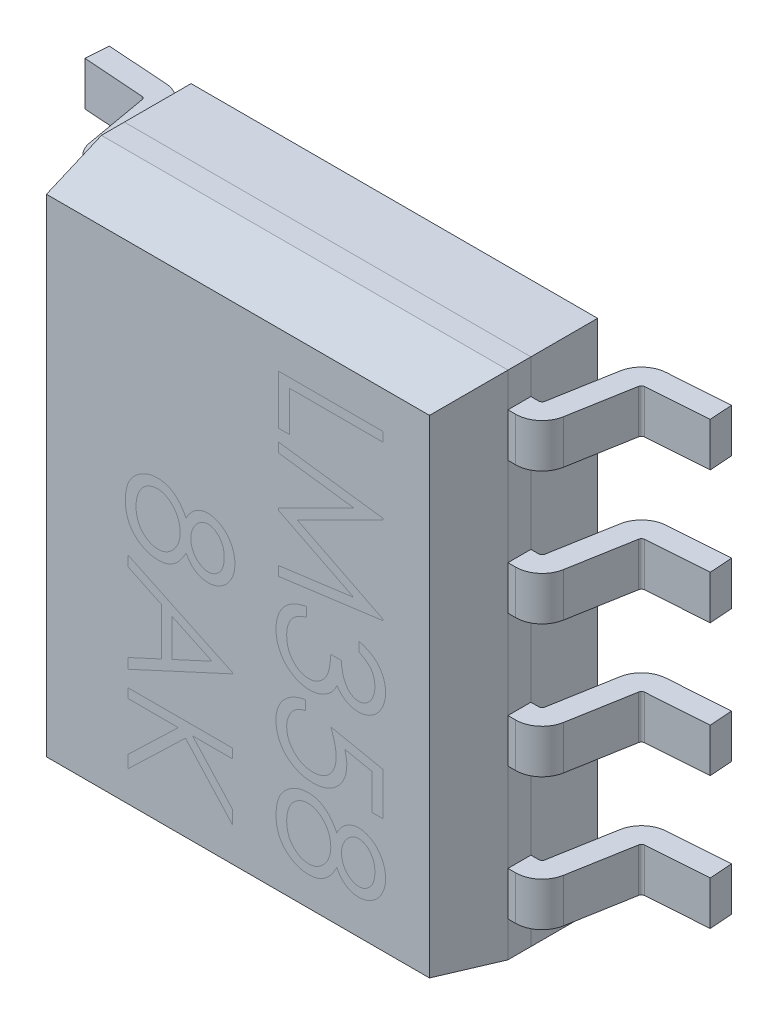
from build123d import *

# Parameters (mm, degrees)
SZKIC1_W                      = 3.9
SZKIC1_H                      = 4.9
DODANIE_WYCI_GNI_CIE1_DEPTH   = 0.22
DODANIE_WYCI_GNI_CIE2_DEPTH   = 0.42
DODANIE_WYCI_GNI_CIE2_2_DEPTH = 0.42
SZYK_LINIOWY1_COUNT           = 4
SZYK_LINIOWY1_PITCH           = 1.27
SZKIC3_W                      = 3.9
SZKIC3_H                      = 4.9
DODANIE_WYCI_GNI_CIE3_DEPTH   = 0.64
DODANIE_WYCI_GNI_CIE3_TAPER   = 10
SZKIC4_W                      = 3.9
SZKIC4_H                      = 4.9
DODANIE_WYCI_GNI_CIE4_DEPTH   = 0.64


with BuildPart() as part:
    # Szkic1 → Dodanie-wyciągnięcie1 (new body)
    with BuildSketch(Plane.XY):
        Rectangle(SZKIC1_W, SZKIC1_H)
    extrude(amount=DODANIE_WYCI_GNI_CIE1_DEPTH)

    # Szkic3 → Dodanie-wyciągnięcie3 (add)
    with BuildSketch(Plane.XY.offset(0.22)):
        Rectangle(SZKIC3_W, SZKIC3_H)
    extrude(amount=DODANIE_WYCI_GNI_CIE3_DEPTH, taper=DODANIE_WYCI_GNI_CIE3_TAPER)


with BuildPart() as body_2:
    # Szkic2 → Dodanie-wyciągnięcie2 (new body)
    with BuildSketch(Plane(origin=(0, -2.11, 0), x_dir=(-1, 0, 0), z_dir=(0, -1, 0))):
        with BuildLine():
            Line((1.95, 0), (1.95, -0.22))
            Line((1.95, -0.22), (2.023994328, -0.22))
            ThreePointArc((2.023994328, -0.22), (2.186976659, -0.160679283), (2.273697746, -0.010473954))
            Line((2.273697746, -0.010473954), (2.381657706, 0.601797401))
            ThreePointArc((2.381657706, 0.601797401), (2.392250409, 0.620907143), (2.412362705, 0.629444306))
            Line((2.412362705, 0.629444306), (3, 0.670535909))
            Line((3, 0.670535909), (2.984653576, 0.89))
            Line((2.984653576, 0.89), (2.397016281, 0.848908397))
            ThreePointArc((2.397016281, 0.848908397), (2.245041675, 0.784399005), (2.165, 0.64))
            Line((2.165, 0.64), (2.057040041, 0.027728645))
            ThreePointArc((2.057040041, 0.027728645), (2.045563385, 0.007850495), (2.023994328, 0))
            Line((2.023994328, 0), (1.95, 0))
        make_face()
    extrude(amount=-DODANIE_WYCI_GNI_CIE2_DEPTH)


with BuildPart() as body_3:
    # Szkic2 → Dodanie-wyci_gni_cie2 2 (new body)
    with BuildSketch(Plane(origin=(0, -2.11, 0), x_dir=(-1, 0, 0), z_dir=(0, -1, 0))):
        with BuildLine():
            Line((-1.95, -0.22), (-1.95, 0))
            Line((-1.95, 0), (-2.023994328, 0))
            ThreePointArc((-2.023994328, 0), (-2.045563385, 0.007850495), (-2.057040041, 0.027728645))
            Line((-2.057040041, 0.027728645), (-2.165, 0.64))
            ThreePointArc((-2.165, 0.64), (-2.245041675, 0.784399005), (-2.397016281, 0.848908397))
            Line((-2.397016281, 0.848908397), (-2.984653576, 0.89))
            Line((-2.984653576, 0.89), (-3, 0.670535909))
            Line((-3, 0.670535909), (-2.412362705, 0.629444306))
            ThreePointArc((-2.412362705, 0.629444306), (-2.392250409, 0.620907143), (-2.381657706, 0.601797401))
            Line((-2.381657706, 0.601797401), (-2.273697746, -0.010473954))
            ThreePointArc((-2.273697746, -0.010473954), (-2.186976659, -0.160679283), (-2.023994328, -0.22))
            Line((-2.023994328, -0.22), (-1.95, -0.22))
        make_face()
    extrude(amount=-DODANIE_WYCI_GNI_CIE2_2_DEPTH)


with BuildPart() as szyk_liniowy1_1:
    # Szyk liniowy1: pattern copy
    add(body_3.part.moved(Location(Vector(0, 1, 0) * (1 * SZYK_LINIOWY1_PITCH))))


with BuildPart() as szyk_liniowy1_2:
    # Szyk liniowy1: pattern copy
    add(body_3.part.moved(Location(Vector(0, 1, 0) * (2 * SZYK_LINIOWY1_PITCH))))


with BuildPart() as szyk_liniowy1_3:
    # Szyk liniowy1: pattern copy
    add(body_3.part.moved(Location(Vector(0, 1, 0) * (3 * SZYK_LINIOWY1_PITCH))))


with BuildPart() as szyk_liniowy1_4:
    # Szyk liniowy1: pattern copy
    add(body_2.part.moved(Location(Vector(0, 1, 0) * (1 * SZYK_LINIOWY1_PITCH))))


with BuildPart() as szyk_liniowy1_5:
    # Szyk liniowy1: pattern copy
    add(body_2.part.moved(Location(Vector(0, 1, 0) * (2 * SZYK_LINIOWY1_PITCH))))


with BuildPart() as szyk_liniowy1_6:
    # Szyk liniowy1: pattern copy
    add(body_2.part.moved(Location(Vector(0, 1, 0) * (3 * SZYK_LINIOWY1_PITCH))))


with BuildPart() as body_10:
    # Szkic4 → Dodanie-wyciągnięcie4 (new body)
    with BuildSketch(Plane(origin=(0, 0, 0), x_dir=(-1, 0, 0), z_dir=(0, 0, -1))):
        Rectangle(SZKIC4_W, SZKIC4_H)
    extrude(amount=DODANIE_WYCI_GNI_CIE4_DEPTH)


solid = Compound([part.part, body_2.part, body_3.part, szyk_liniowy1_1.part, szyk_liniowy1_2.part, szyk_liniowy1_3.part, szyk_liniowy1_4.part, szyk_liniowy1_5.part, szyk_liniowy1_6.part, body_10.part])
